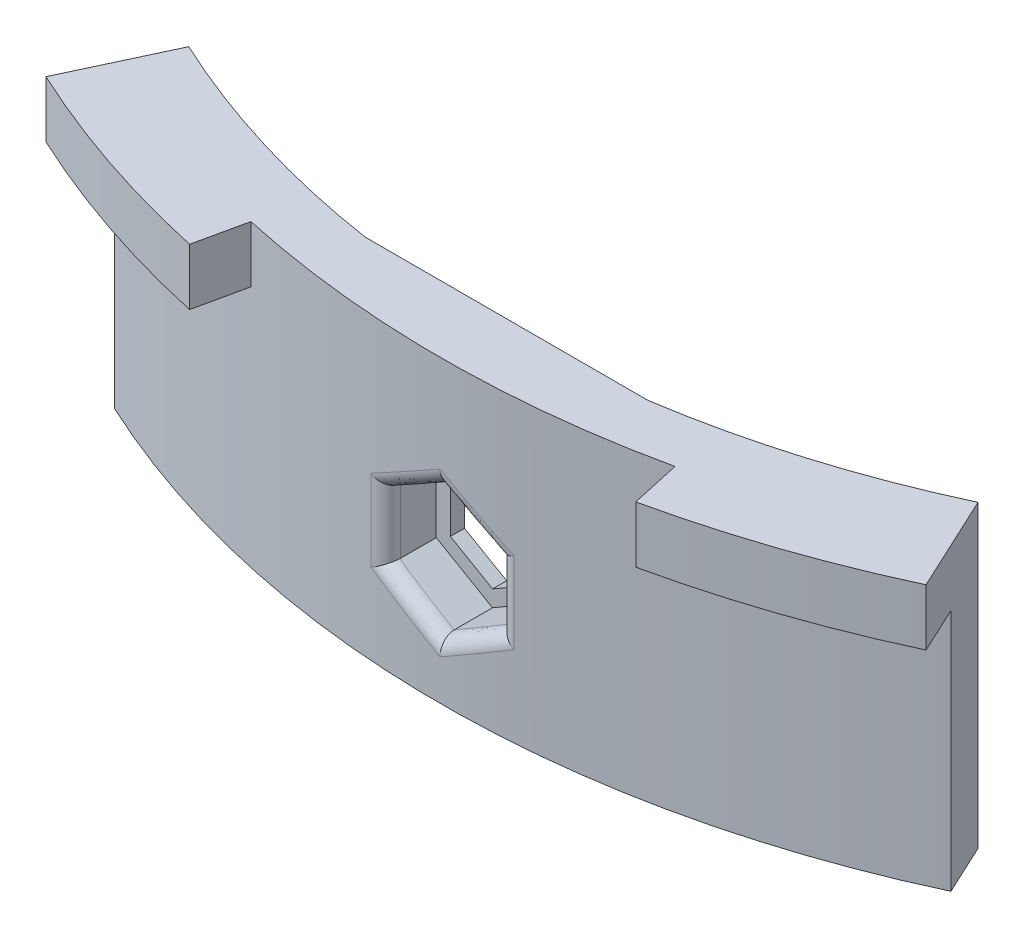
from build123d import *

# Parameters (mm, degrees)
SKETCH1_W                    = 25.4
SKETCH1_H                    = 21.844
BOLT_SIZE_WIDTH_HEIGHT_DEPTH = 7.62
FRONT_CURVE_DEPTH            = 22.844
SKETCH3_W                    = 25.4
SKETCH3_H                    = 21.844
REAR_CAP_DEPTH               = 1.27
WINGS_DEPTH                  = 21.844
HOOK_DEPTH_DEPTH             = 5.08
HOOK_HEIGHT_DEPTH            = 3.81
NUT_FLANGE_CLEARANCE_R       = 1.27
DECORATION_SIZE              = 2.54
CUT_EXTRUDE1_DEPTH           = 27.9240001


with BuildPart() as part:
    # Sketch1 → Bolt Size, Width, &Height (new body)
    with BuildSketch(Plane.XY):
        Rectangle(SKETCH1_W, SKETCH1_H)
        Polygon((0, 5.842), (-5.059320409, 2.921), (-5.059320409, -2.921), (0, -5.842), (5.059320409, -2.921), (5.059320409, 2.921), align=None, mode=Mode.SUBTRACT)
    extrude(amount=BOLT_SIZE_WIDTH_HEIGHT_DEPTH)

    # Sketch2 → Front Curve (cut, through all)
    with BuildSketch(Plane(origin=(0, 10.922, 0), x_dir=(1, 0, 0), z_dir=(0, 1, 0))):
        with BuildLine():
            Line((12.7, -7.62), (12.7, -3.81))
            ThreePointArc((12.7, -3.81), (0, -4.721818976), (-12.7, -3.81))
            Line((-12.7, -3.81), (-12.7, -7.62))
            Line((-12.7, -7.62), (12.7, -7.62))
        make_face()
    extrude(amount=-FRONT_CURVE_DEPTH, mode=Mode.SUBTRACT)

    # Sketch3 → Rear Cap (add)
    with BuildSketch(Plane(origin=(0, 0, 0), x_dir=(-1, 0, 0), z_dir=(0, 0, -1))):
        Rectangle(SKETCH3_W, SKETCH3_H)
        Polygon((-3.789320409, 2.187765158), (-3.789320409, -2.187765158), (0, -4.375530316), (3.789320409, -2.187765158), (3.789320409, 2.187765158), (0, 4.375530316), align=None, mode=Mode.SUBTRACT)
    extrude(amount=REAR_CAP_DEPTH)

    # Sketch6 → Wings (add)
    with BuildSketch(Plane.XZ.offset(10.922)):
        with BuildLine():
            ThreePointArc((-12.7, 3.81), (-25.407517395, 1.013767303), (-37.570763469, -3.607418757))
            Line((-37.570763469, -3.607418757), (-35.447209633, -8.161394654))
            ThreePointArc((-35.447209633, -8.161394654), (-24.318948968, -3.905861998), (-12.7, -1.27))
            Line((-12.7, -1.27), (-12.7, 3.81))
        make_face()
        with BuildLine():
            ThreePointArc((37.570763469, -3.607418757), (25.407517395, 1.013767303), (12.7, 3.81))
            Line((12.7, 3.81), (12.7, -1.27))
            ThreePointArc((12.7, -1.27), (24.318948968, -3.905861998), (35.447209633, -8.161394654))
            Line((35.447209633, -8.161394654), (37.570763469, -3.607418757))
        make_face()
    extrude(amount=-WINGS_DEPTH)

    # Sketch7 → Hook Depth (add)
    with BuildSketch(Plane(origin=(0, 10.922, 0), x_dir=(1, 0, 0), z_dir=(0, 1, 0))):
        with BuildLine():
            Line((12.7, 1.27), (-12.7, 1.27))
            ThreePointArc((-12.7, 1.27), (-24.318948968, 3.905861998), (-35.447209633, 8.161394654))
            Line((-35.447209633, 8.161394654), (-40.59977148, -2.888309885))
            ThreePointArc((-40.59977148, -2.888309885), (-30.779461435, -6.824786165), (-20.585837904, -9.657518799))
            Line((-20.585837904, -9.657518799), (-19.05, -2.656762978))
            ThreePointArc((-19.05, -2.656762978), (0, -4.721818976), (19.05, -2.656762978))
            Line((19.05, -2.656762978), (20.585837904, -9.657518799))
            ThreePointArc((20.585837904, -9.657518799), (30.779461435, -6.824786165), (40.59977148, -2.888309885))
            Line((40.59977148, -2.888309885), (35.447209633, 8.161394654))
            ThreePointArc((35.447209633, 8.161394654), (24.318948968, 3.905861998), (12.7, 1.27))
        make_face()
    extrude(amount=HOOK_DEPTH_DEPTH)

    # Sketch8 → Hook Height (add)
    with BuildSketch(Plane.XZ.offset(-10.922)):
        with BuildLine():
            ThreePointArc((-20.585837904, 9.657518799), (-30.779461435, 6.824786165), (-40.59977148, 2.888309885))
            Line((-40.59977148, 2.888309885), (-39.526321095, 0.586288106))
            ThreePointArc((-39.526321095, 0.586288106), (-29.965658216, 4.418684687), (-20.04155219, 7.176520399))
            Line((-20.04155219, 7.176520399), (-20.585837904, 9.657518799))
        make_face()
        with BuildLine():
            Line((39.526321095, 0.586288106), (40.59977148, 2.888309885))
            ThreePointArc((40.59977148, 2.888309885), (30.779461435, 6.824786165), (20.585837904, 9.657518799))
            Line((20.585837904, 9.657518799), (20.04155219, 7.176520399))
            ThreePointArc((20.04155219, 7.176520399), (29.965658216, 4.418684687), (39.526321095, 0.586288106))
        make_face()
    extrude(amount=HOOK_HEIGHT_DEPTH)

    # Nut Flange Clearance
    nut_flange_clearance_edges = [part.edges().sort_by_distance(p)[0] for p in [
        (5.059320409, 0, 4.577738649),
        (2.530429584, 4.381055799, 4.685798889),
        (-2.530429584, 4.381055799, 4.685798889),
        (-5.059320409, 0, 4.577738649),
        (-2.530429584, -4.381055799, 4.685798889),
        (2.530429584, -4.381055799, 4.685798889),
    ]]
    fillet(nut_flange_clearance_edges, radius=NUT_FLANGE_CLEARANCE_R)

    # Decoration
    decoration_edges = [part.edges().sort_by_distance(p)[0] for p in [
        (-40.063046287, 7.112, 1.737298996),
        (-20.313695047, 7.112, 8.417019599),
        (40.063046287, 7.112, 1.737298996),
        (20.313695047, 7.112, 8.417019599),
    ]]
    chamfer(decoration_edges, length=DECORATION_SIZE)

    # Sketch9 → Cut-Extrude1 (cut, through all)
    with BuildSketch(Plane(origin=(0, 16.002, 0), x_dir=(1, 0, 0), z_dir=(0, 1, 0))):
        with BuildLine():
            Line((40.59977148, -2.888309885), (39.526321095, -0.586288106))
            ThreePointArc((39.526321095, -0.586288106), (0, -9.349062527), (-39.526321095, -0.586288106))
            Line((-39.526321095, -0.586288106), (-40.59977148, -2.888309885))
            ThreePointArc((-40.59977148, -2.888309885), (0, -11.889062527), (40.59977148, -2.888309885))
        make_face()
    extrude(amount=-CUT_EXTRUDE1_DEPTH, mode=Mode.SUBTRACT)


solid = part.part
